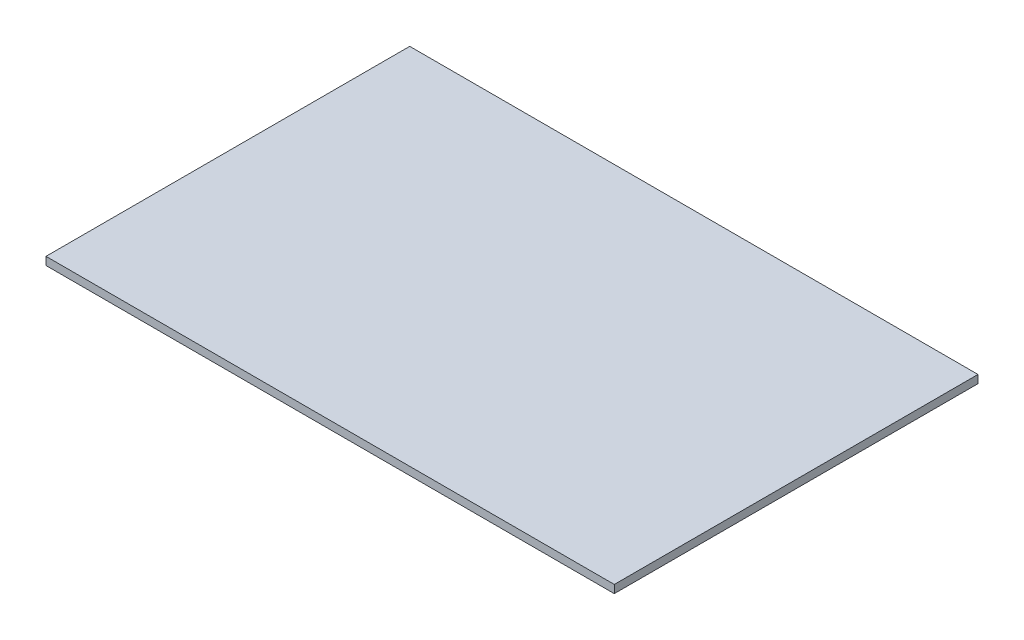
from build123d import *

# Parameters (mm, degrees)
SKETCH1_W           = 1270
SKETCH1_H           = 812.8
BOSS_EXTRUDE1_DEPTH = 17.8816


with BuildPart() as part:
    # Sketch1 → Boss-Extrude1 (new body)
    with BuildSketch(Plane(origin=(0, 0, 0), x_dir=(1, 0, 0), z_dir=(0, 1, 0))):
        Rectangle(SKETCH1_W, SKETCH1_H)
    extrude(amount=BOSS_EXTRUDE1_DEPTH)


solid = part.part
